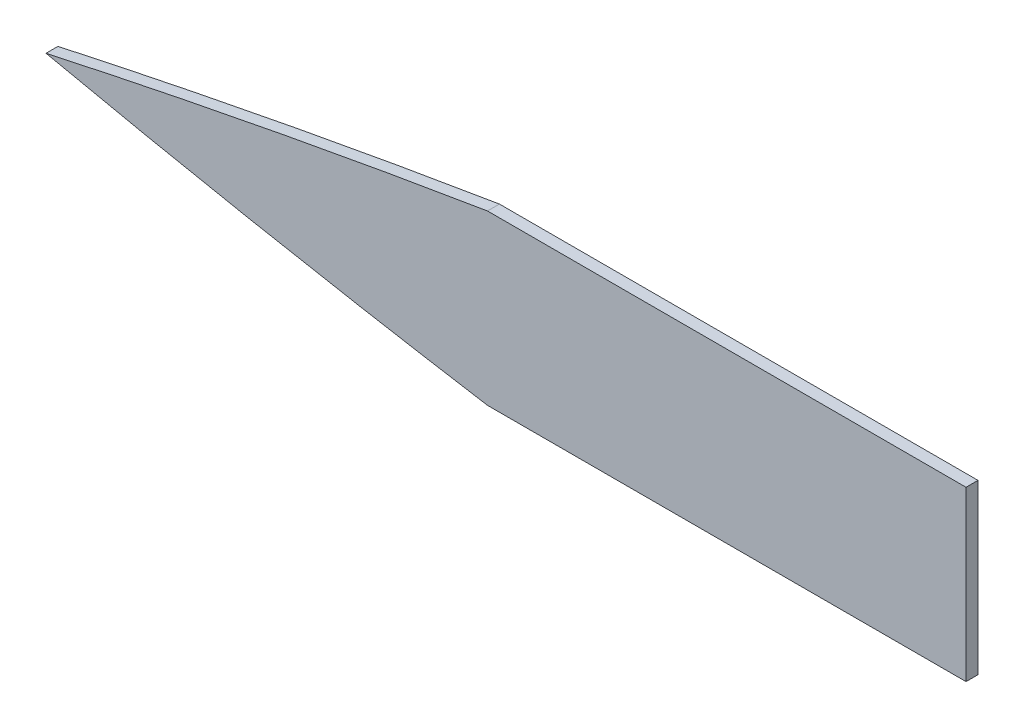
from build123d import *

# Parameters (mm, degrees)
BOSS_EXTRUDE1_DEPTH      = 1.25
BOSS_EXTRUDE1_DEPTH_BACK = 1.25


with BuildPart() as part:
    # Sketch2 → Boss-Extrude1 (new, two sides: drawn at the far end of the back side and taken through both)
    with BuildSketch(Plane.XY.offset(-BOSS_EXTRUDE1_DEPTH_BACK)):
        with BuildLine():
            Line((98.502891266, 17.588765104), (198.502891266, 17.588765104))
            Line((198.502891266, 17.588765104), (198.502891266, -17.588765104))
            Line((198.502891266, -17.588765104), (98.502891266, -17.588765104))
            add(Edge.make_bspline(
                [(6.253387475, 0), (52.148844411, -9.975392509), (98.502891266, -17.588765104)],
                knots=[0, 0, 0, 1, 1, 1], degree=2))
            add(Edge.make_bspline(
                [(6.253387475, 0), (52.148844411, 9.975392509), (98.502891266, 17.588765104)],
                knots=[0, 0, 0, 1, 1, 1], degree=2))
        make_face()
    extrude(amount=BOSS_EXTRUDE1_DEPTH + BOSS_EXTRUDE1_DEPTH_BACK)


solid = part.part
